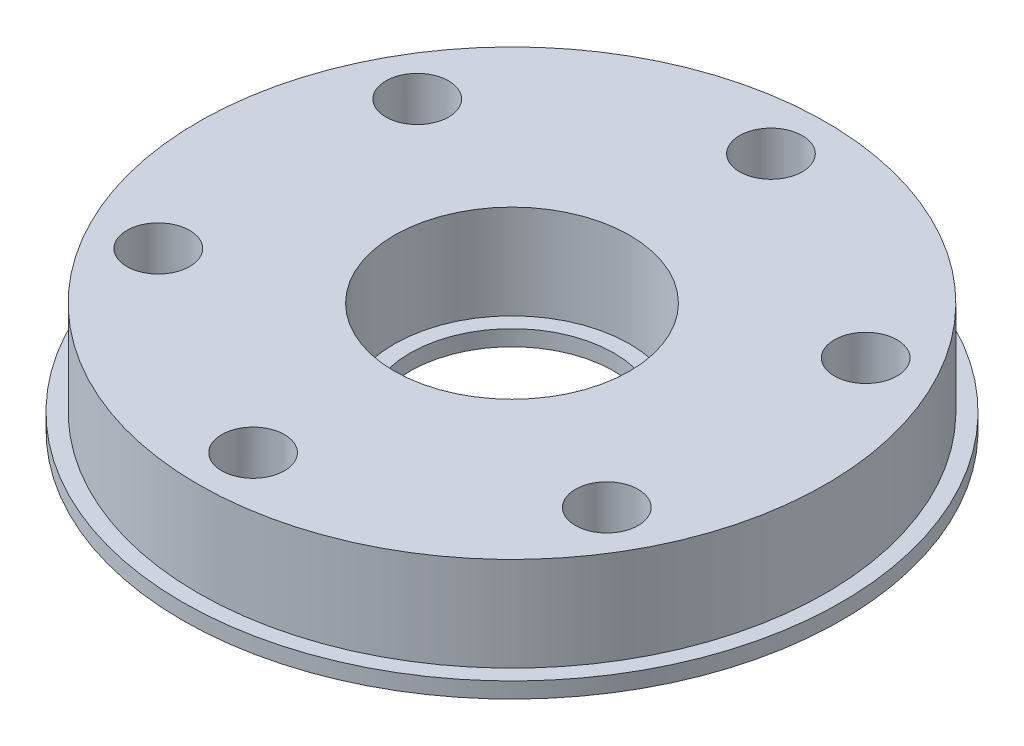
from build123d import *

# Parameters (mm, degrees)
SKETCH1_R           = 20
SKETCH1_R_2         = 7.5
BOSS_EXTRUDE1_DEPTH = 6
SKETCH2_R           = 2
CUT_EXTRUDE1_DEPTH  = 7
CIRPATTERN2_COUNT   = 6
SKETCH3_R           = 21
SKETCH3_R_2         = 6.5
SKETCH3_R_3         = 2
BOSS_EXTRUDE2_DEPTH = 1


with BuildPart() as part:
    # Sketch1 → Boss-Extrude1 (new body)
    with BuildSketch(Plane(origin=(0, 0, 0), x_dir=(1, 0, 0), z_dir=(0, 1, 0))):
        Circle(SKETCH1_R)
        Circle(SKETCH1_R_2, mode=Mode.SUBTRACT)
    extrude(amount=BOSS_EXTRUDE1_DEPTH)

    # Sketch2 → Cut-Extrude1 (cut, through all)
    with BuildSketch(Plane(origin=(0, 6, 0), x_dir=(1, 0, 0), z_dir=(0, 1, 0))):
        with Locations((0, 16.5)):
            Circle(SKETCH2_R)
    cut_extrude1 = extrude(amount=-CUT_EXTRUDE1_DEPTH, mode=Mode.SUBTRACT)

    # CirPattern2: Cut-Extrude1 ×6 about axis
    cirpattern2_axis = Axis((0, 0, 0), (0, 1, 0))
    for i in range(1, CIRPATTERN2_COUNT):
        add(cut_extrude1.rotate(cirpattern2_axis, i * 360 / CIRPATTERN2_COUNT), mode=Mode.SUBTRACT)

    # Sketch3 → Boss-Extrude2 (add)
    with BuildSketch(Plane(origin=(0, 0, 0), x_dir=(1, 0, 0), z_dir=(0, 1, 0))):
        Circle(SKETCH3_R)
        Circle(SKETCH3_R_2, mode=Mode.SUBTRACT)
        with Locations((-14.289419162, -8.25)):
            Circle(SKETCH3_R_3, mode=Mode.SUBTRACT)
        with Locations((0, -16.5)):
            Circle(SKETCH3_R_3, mode=Mode.SUBTRACT)
        with Locations((14.289419162, -8.25)):
            Circle(SKETCH3_R_3, mode=Mode.SUBTRACT)
        with Locations((14.289419162, 8.25)):
            Circle(SKETCH3_R_3, mode=Mode.SUBTRACT)
        with Locations((0, 16.5)):
            Circle(SKETCH3_R_3, mode=Mode.SUBTRACT)
        with Locations((-14.289419162, 8.25)):
            Circle(SKETCH3_R_3, mode=Mode.SUBTRACT)
    extrude(amount=-BOSS_EXTRUDE2_DEPTH)


solid = part.part
